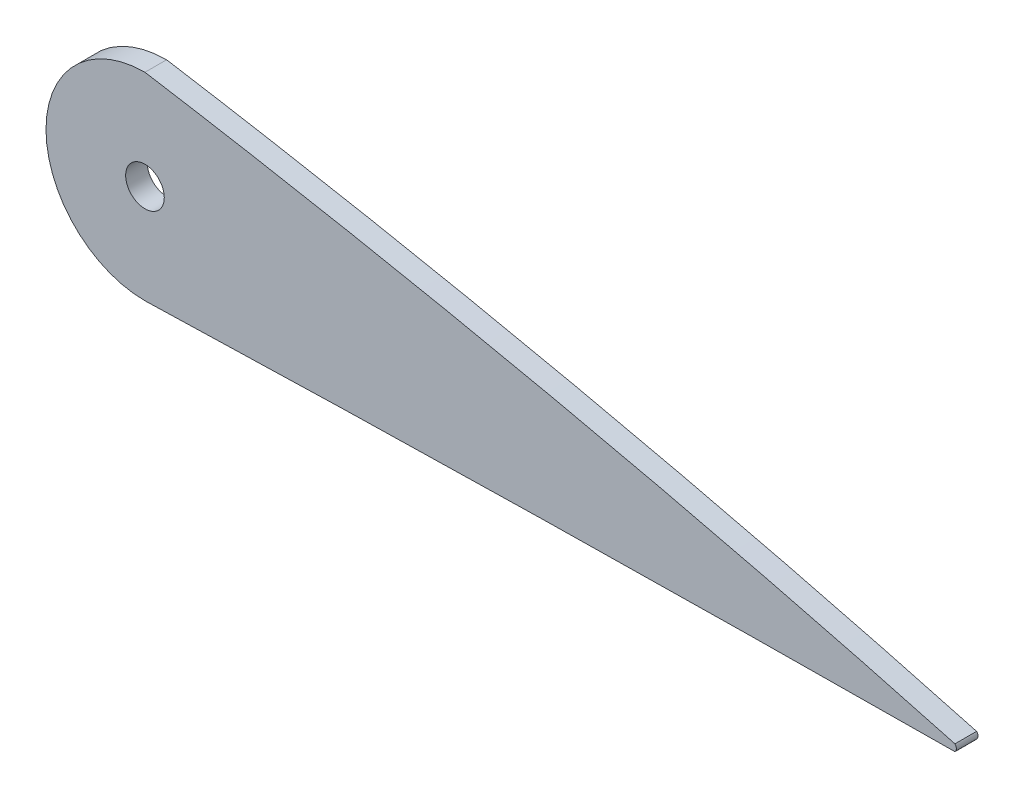
from build123d import *

# Parameters (mm, degrees)
SKETCH_2_R      = 2.5
EXTRUDE_1_DEPTH = 1.4


with BuildPart() as part:
    # Эскиз2 → Бобышка-Вытянуть1 (new body, symmetric)
    with BuildSketch(Plane.XY):
        with BuildLine():
            ThreePointArc((350, 0.441), (350.182668182, 0), (350, -0.441))
            add(Edge.make_bspline(
                [(245.182668182, -2.318077567), (248.299487738, -2.222776548), (254.6148421, -2.036682455), (264.128528247, -1.778536728), (273.723303235, -1.541558038), (283.317346051, -1.328064065), (292.909735844, -1.138021673), (302.493517153, -0.971016602), (312.041013985, -0.826421034), (321.464682241, -0.704096652), (330.522295396, -0.604119869), (338.773087678, -0.527128646), (345.182558015, -0.475350241), (348.76868735, -0.44977974), (350, -0.441)],
                knots=[0.704555577, 0.704555577, 0.704555577, 0.704555577, 0.730918775, 0.757971338, 0.785017763, 0.812061651, 0.839103366, 0.866131651, 0.893099152, 0.919831065, 0.945809917, 0.969680601, 0.989589706, 1, 1, 1, 1], degree=3))
            ThreePointArc((245.182668182, -2.318077567), (232.376774993, 10.487815621), (245.182668182, 23.29370881))
            add(Edge.make_bspline(
                [(350, 0.441), (348.817934836, 0.763027745), (345.408245977, 1.69192274), (339.347864917, 3.301674674), (331.589665686, 5.302675511), (323.091885591, 7.417212373), (314.238285126, 9.538012439), (305.242760894, 11.608254886), (296.187367062, 13.60762908), (287.101376113, 15.529324906), (277.995159278, 17.370991017), (268.873317879, 19.131417094), (259.738667962, 20.809730625), (251.840157462, 22.18732961), (246.985652296, 22.997756578), (245.182668182, 23.29370881)],
                knots=[0, 0, 0, 0, 0.0101622, 0.029313053, 0.052011605, 0.076619468, 0.101948061, 0.127526132, 0.153184131, 0.178867888, 0.204557903, 0.230245712, 0.255925967, 0.281594302, 0.296749598, 0.296749598, 0.296749598, 0.296749598], degree=3))
        make_face()
        with Locations((245.182668182, 10.487815621)):
            Circle(SKETCH_2_R, mode=Mode.SUBTRACT)
    extrude(amount=EXTRUDE_1_DEPTH, both=True)


solid = part.part
